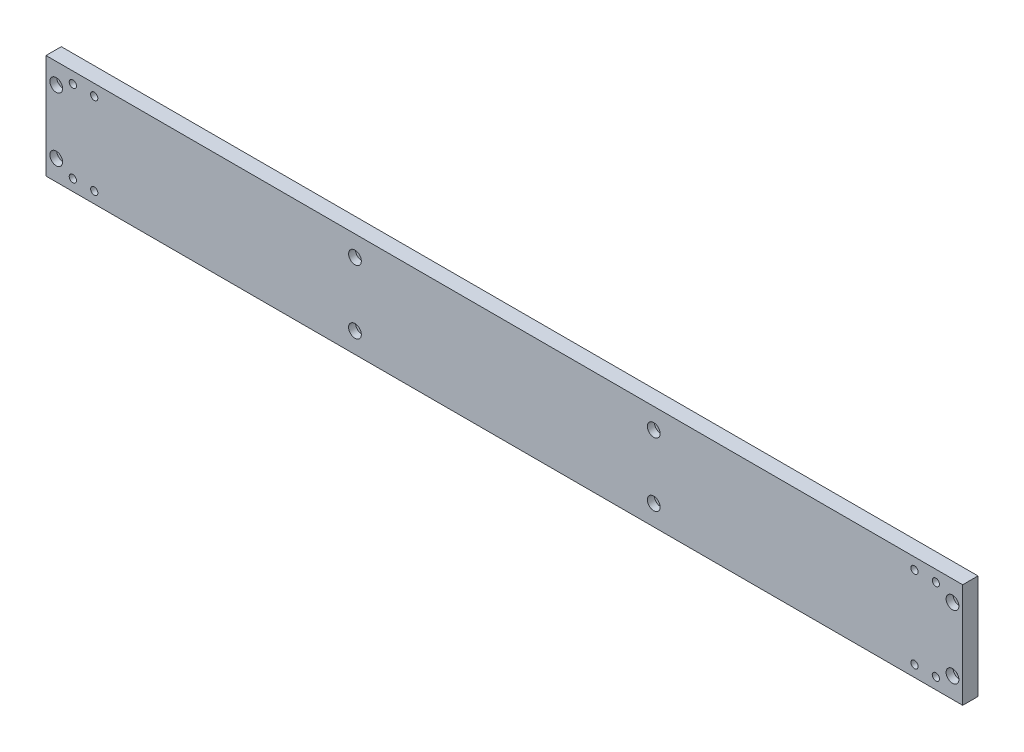
from build123d import *

# Parameters (mm, degrees)
ESBO_O1_W                                            = 570.475
ESBO_O1_H                                            = 65
RESSALTO_EXTRUS_O1_DEPTH                             = 9.525
REBAIXO_PARA_PARAFUSO_DE_M_QUINA_DE_CABE_D           = 4.4958
REBAIXO_PARA_PARAFUSO_DE_M_QUINA_DE_CABE_DEPTH       = 9.525
REBAIXO_PARA_PARAFUSO_DE_M_QUINA_DE_CABE_CBORE_D     = 7.9375
REBAIXO_PARA_PARAFUSO_DE_M_QUINA_DE_CABE_CBORE_DEPTH = 4.318
REBAIXO_PARA_PARAFUSO_DE_M_QUINA_DE_2_D              = 4.4958
REBAIXO_PARA_PARAFUSO_DE_M_QUINA_DE_2_DEPTH          = 9.525
REBAIXO_PARA_PARAFUSO_DE_M_QUINA_DE_2_CBORE_D        = 7.9375
REBAIXO_PARA_PARAFUSO_DE_M_QUINA_DE_2_CBORE_DEPTH    = 4.318


with BuildPart() as part:
    # Esboço1 → Ressalto-extrusão1 (new body)
    with BuildSketch(Plane.XY.offset(9.525)):
        with Locations((285.2375, 32.5)):
            Rectangle(ESBO_O1_W, ESBO_O1_H)
    extrude(amount=-RESSALTO_EXTRUS_O1_DEPTH)

    # Rebaixo para parafuso de m_quina de cabe
    with Locations(Plane(origin=(0, 0, 0), x_dir=(-1, 0, 0), z_dir=(0, 0, -1))):
        with Locations((-30, 7), (-16.7, 7), (-16.7, 58), (-30, 58), (-540.475, 58), (-553.775, 58), (-553.775, 7), (-540.475, 7)):
            CounterBoreHole(REBAIXO_PARA_PARAFUSO_DE_M_QUINA_DE_CABE_D / 2, REBAIXO_PARA_PARAFUSO_DE_M_QUINA_DE_CABE_CBORE_D / 2, REBAIXO_PARA_PARAFUSO_DE_M_QUINA_DE_CABE_CBORE_DEPTH, depth=REBAIXO_PARA_PARAFUSO_DE_M_QUINA_DE_CABE_DEPTH)

    # Rebaixo para parafuso de m_quina de  2
    with Locations(Plane.XY.offset(9.525)):
        with Locations((6.35, 52.3), (6.35, 12.7), (192.275, 52.3), (192.275, 12.7), (378.2, 52.3), (378.2, 12.7), (564.125, 52.3), (564.125, 12.7)):
            CounterBoreHole(REBAIXO_PARA_PARAFUSO_DE_M_QUINA_DE_2_D / 2, REBAIXO_PARA_PARAFUSO_DE_M_QUINA_DE_2_CBORE_D / 2, REBAIXO_PARA_PARAFUSO_DE_M_QUINA_DE_2_CBORE_DEPTH, depth=REBAIXO_PARA_PARAFUSO_DE_M_QUINA_DE_2_DEPTH)


solid = part.part
